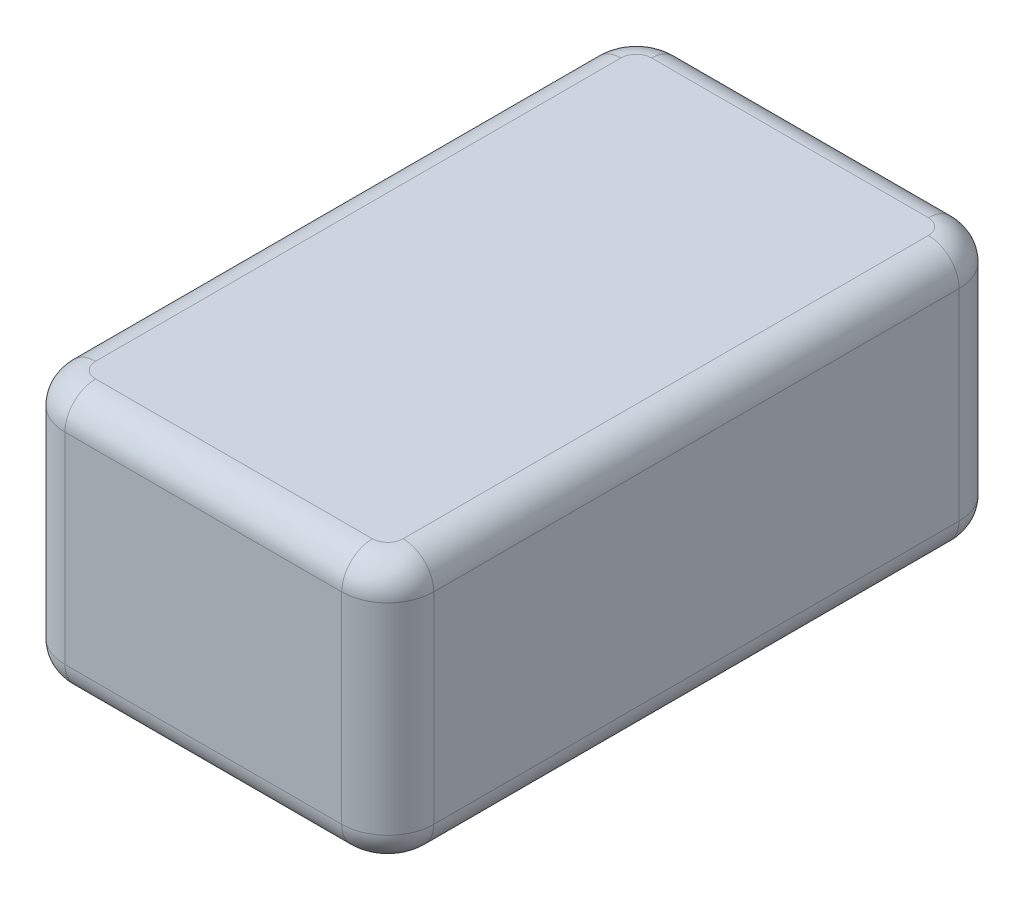
from build123d import *

# Parameters (mm, degrees)
SKETCH1_W           = 305.308
SKETCH1_H           = 511.048
BOSS_EXTRUDE1_DEPTH = 217.424
FILLET1_R           = 38.1
FILLET2_R           = 25.4


with BuildPart() as part:
    # Sketch1 → Boss-Extrude1 (new body)
    with BuildSketch(Plane(origin=(0, 0, 0), x_dir=(1, 0, 0), z_dir=(0, 1, 0))):
        with Locations((152.654, 255.524)):
            Rectangle(SKETCH1_W, SKETCH1_H)
    extrude(amount=BOSS_EXTRUDE1_DEPTH)

    # Fillet1
    fillet1_edges = [part.edges().sort_by_distance(p)[0] for p in [
        (0, 108.712, -511.048),
        (305.308, 108.712, -511.048),
        (305.308, 108.712, 0),
        (0, 108.712, 0),
    ]]
    fillet(fillet1_edges, radius=FILLET1_R)

    # Fillet2
    fillet2_edges = [part.edges().sort_by_distance(p)[0] for p in [
        (152.654, 0, -511.048),
        (152.654, 217.424, -511.048),
        (0, 0, -255.524),
        (305.308, 0, -255.524),
        (152.654, 0, 0),
        (11.159231637, 0, -11.159231637),
        (294.148768363, 0, -11.159231637),
        (11.159231637, 0, -499.888768363),
        (294.148768363, 0, -499.888768363),
        (305.308, 217.424, -255.524),
        (0, 217.424, -255.524),
        (152.654, 217.424, 0),
        (11.159231637, 217.424, -11.159231637),
        (294.148768363, 217.424, -11.159231637),
        (11.159231637, 217.424, -499.888768363),
        (294.148768363, 217.424, -499.888768363),
    ]]
    fillet(fillet2_edges, radius=FILLET2_R)


solid = part.part
